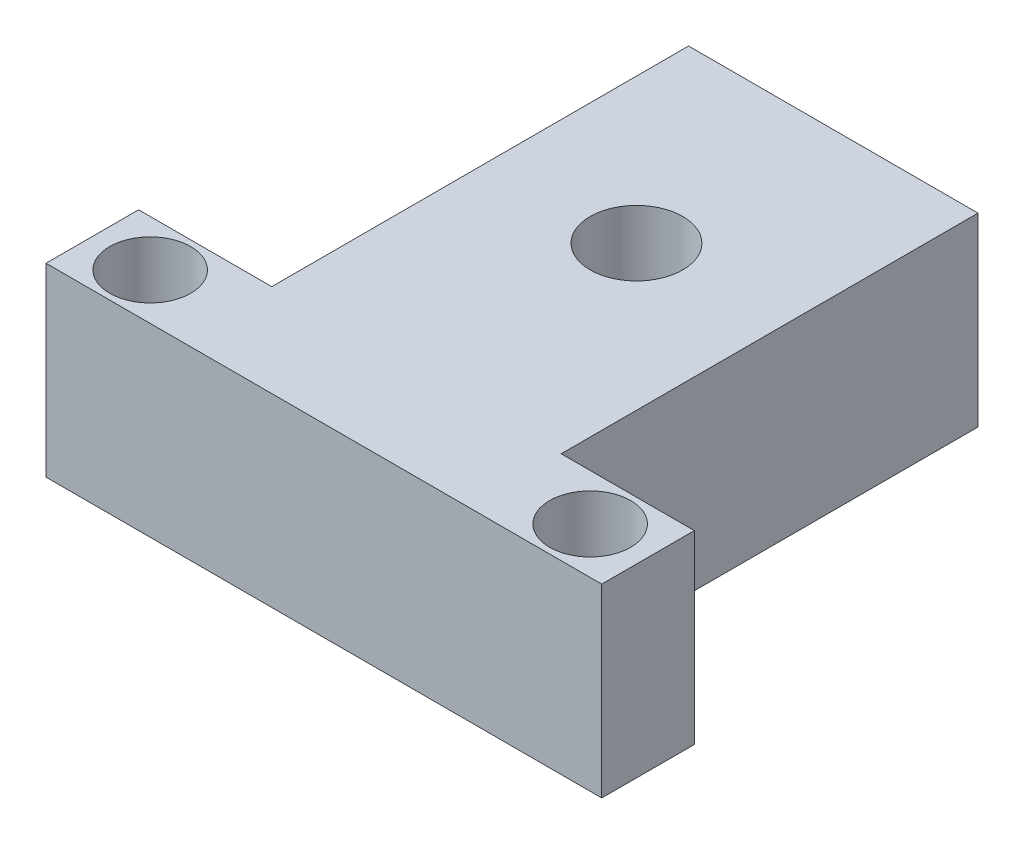
from build123d import *

# Parameters (mm, degrees)
SKETCH1_R           = 3.5
SKETCH1_R_2         = 4
BOSS_EXTRUDE1_DEPTH = 16


with BuildPart() as part:
    # Sketch1 → Boss-Extrude1 (new body)
    with BuildSketch(Plane(origin=(0, 0, 0), x_dir=(1, 0, 0), z_dir=(0, 1, 0))):
        Polygon((0, 0), (48, 0), (48, 8), (36.5, 8), (36.5, 44), (11.5, 44), (11.5, 8), (0, 8), align=None)
        with Locations((5, 4)):
            Circle(SKETCH1_R, mode=Mode.SUBTRACT)
        with Locations((43, 4)):
            Circle(SKETCH1_R, mode=Mode.SUBTRACT)
        with Locations((24, 27)):
            Circle(SKETCH1_R_2, mode=Mode.SUBTRACT)
    extrude(amount=BOSS_EXTRUDE1_DEPTH)


solid = part.part
